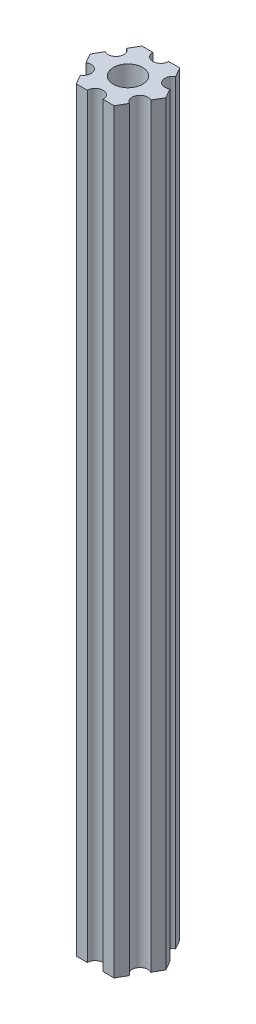
from build123d import *

# Parameters (mm, degrees)
ESBO_O1_R                = 2.79
RESSALTO_EXTRUS_O1_DEPTH = 144


with BuildPart() as part:
    # Esboço1 → Ressalto-extrusão1 (new body)
    with BuildSketch(Plane(origin=(0, 85, 0), x_dir=(1, 0, 0), z_dir=(0, 1, 0))):
        with BuildLine():
            Line((6.162658774, -1.825961894), (7.216878365, 0))
            Line((7.216878365, 0), (6.162658774, 1.825961894))
            ThreePointArc((6.162658774, 1.825961894), (4.113620668, 2.375), (4.662658774, 4.424038106))
            Line((4.662658774, 4.424038106), (3.608439182, 6.25))
            Line((3.608439182, 6.25), (1.5, 6.25))
            ThreePointArc((1.5, 6.25), (0, 4.75), (-1.5, 6.25))
            Line((-1.5, 6.25), (-3.608439182, 6.25))
            Line((-3.608439182, 6.25), (-4.662658774, 4.424038106))
            ThreePointArc((-4.662658774, 4.424038106), (-4.113620668, 2.375), (-6.162658774, 1.825961894))
            Line((-6.162658774, 1.825961894), (-7.216878365, 0))
            Line((-7.216878365, 0), (-6.162658774, -1.825961894))
            ThreePointArc((-6.162658774, -1.825961894), (-4.113620668, -2.375), (-4.662658774, -4.424038106))
            Line((-4.662658774, -4.424038106), (-3.608439182, -6.25))
            Line((-3.608439182, -6.25), (-1.5, -6.25))
            ThreePointArc((-1.5, -6.25), (0, -4.75), (1.5, -6.25))
            Line((1.5, -6.25), (3.608439182, -6.25))
            Line((3.608439182, -6.25), (4.662658774, -4.424038106))
            ThreePointArc((4.662658774, -4.424038106), (4.113620668, -2.375), (6.162658774, -1.825961894))
        make_face()
        Circle(ESBO_O1_R, mode=Mode.SUBTRACT)
    extrude(amount=-RESSALTO_EXTRUS_O1_DEPTH)


solid = part.part
